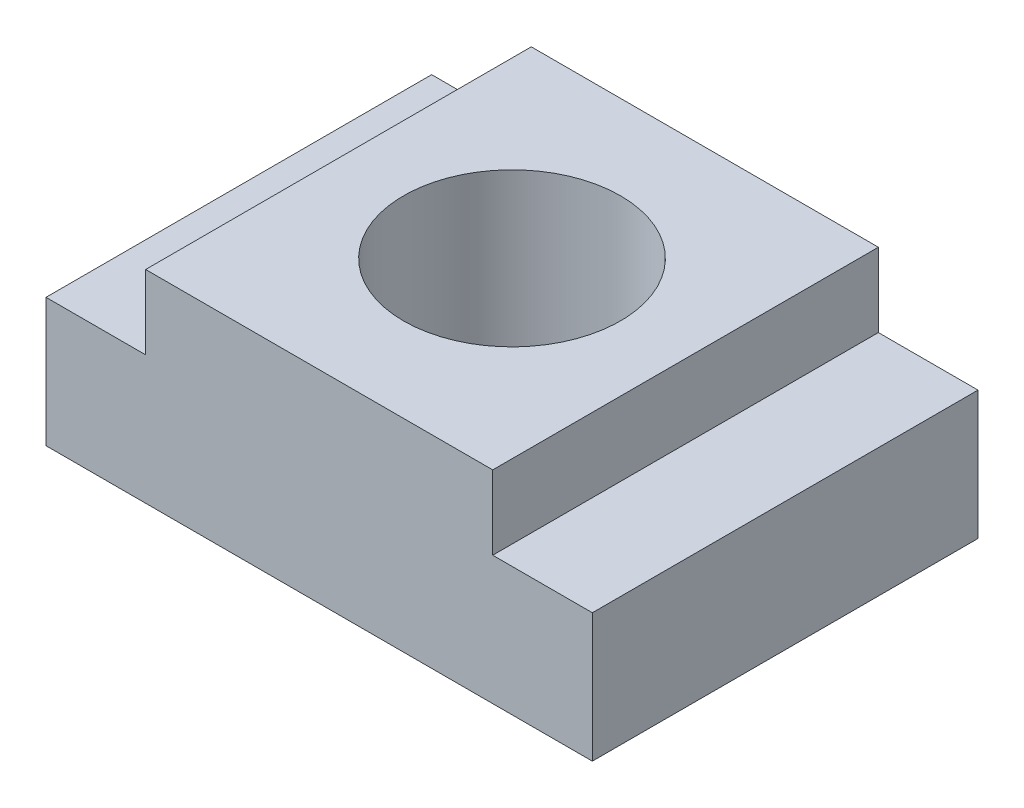
from build123d import *

# Parameters (mm, degrees)
BOSS_EXTRUDE1_DEPTH = 12
SKETCH2_R           = 3.375
CUT_EXTRUDE1_DEPTH  = 7


with BuildPart() as part:
    # Sketch1 → Boss-Extrude1 (new body)
    with BuildSketch(Plane.XY):
        Polygon((0, 6.3), (5.4, 6.3), (5.4, 4), (8.5, 4), (8.5, 0), (0, 0), align=None)
    boss_extrude1 = extrude(amount=BOSS_EXTRUDE1_DEPTH)

    # Mirror1: Boss-Extrude1 across plane
    add(boss_extrude1.mirror(Plane(origin=(0, 0, 0), x_dir=(0, 0, 1), z_dir=(1, 0, 0))))

    # Sketch2 → Cut-Extrude1 (cut)
    with BuildSketch(Plane(origin=(0, 6.3, 0), x_dir=(1, 0, 0), z_dir=(0, 1, 0))):
        with Locations((0, -6)):
            Circle(SKETCH2_R)
    extrude(amount=-CUT_EXTRUDE1_DEPTH, mode=Mode.SUBTRACT)


solid = part.part
